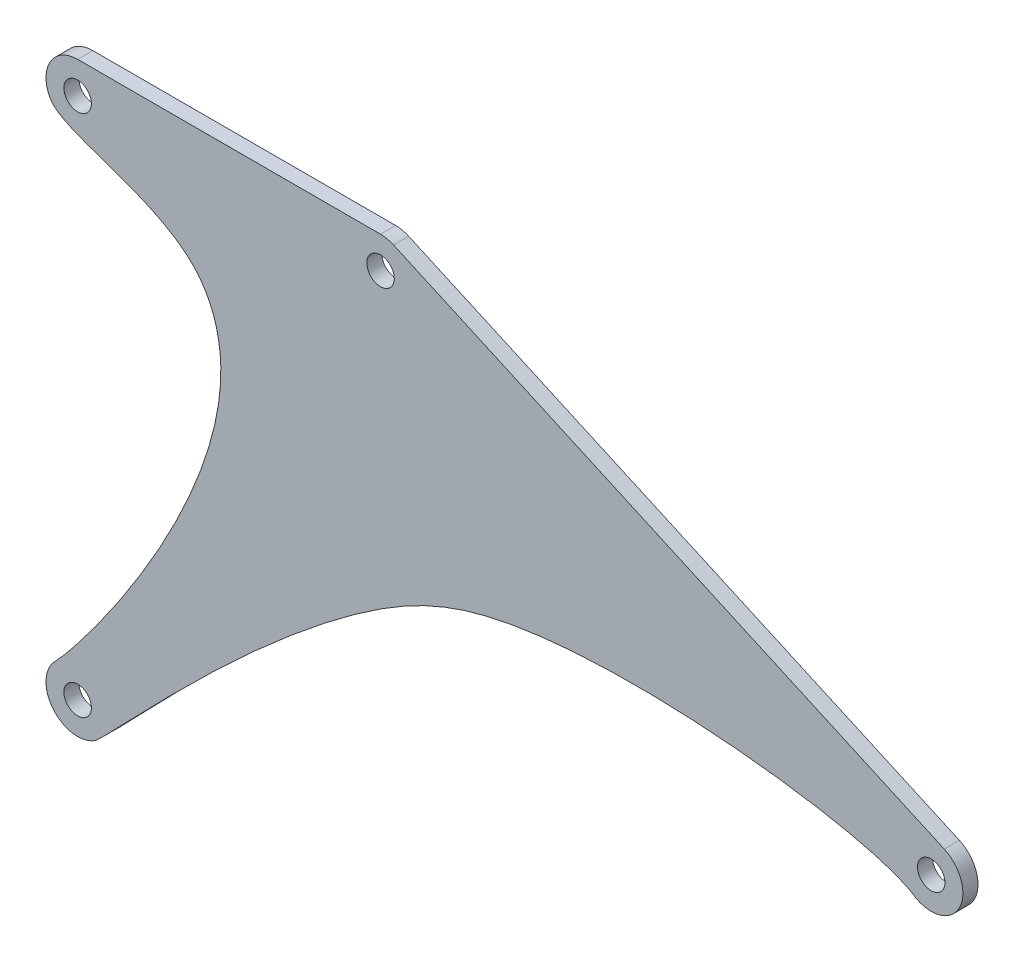
from build123d import *

# Parameters (mm, degrees)
SKETCH1_R       = 5
LINK_BCEF_DEPTH = 2.75


with BuildPart() as part:
    # Sketch1 → link_BCEF (new body, symmetric)
    with BuildSketch(Plane.XY):
        with BuildLine():
            Line((-110, 11.5), (0, 11.5))
            ThreePointArc((0, 11.5), (2.413335963, 11.243923227), (4.719193789, 10.48709731))
            Line((4.719193789, 10.48709731), (204.719193789, -79.51290269))
            ThreePointArc((204.719193789, -79.51290269), (210.037033264, -95.613195459), (193.535322949, -99.510938472))
            add(Edge.make_bspline(
                [(-103.605175934, -199.558045049), (-99.166641345, -196.588436969), (-37.747767195, -126.045876693), (58.834709745, -72.841025291), (177.378760182, -88.529166185), (193.535322949, -99.510938472)],
                knots=[0, 0, 0, 0, 0.472274196, 0.59836262, 1, 1, 1, 1], degree=3))
            ThreePointArc((-103.605175934, -199.558045049), (-118.826673208, -197.371556151), (-118.265297035, -182.004071979))
            add(Edge.make_bspline(
                [(-119.914835658, -5.8263225), (-114.934982102, -14.300695419), (-66.448192668, -18.69275386), (-46.813712441, -89.406939193), (-106.083618348, -169.412013562), (-118.265297035, -182.004071979)],
                knots=[0, 0, 0, 0, 0.300298834, 0.455611494, 1, 1, 1, 1], degree=3))
            ThreePointArc((-119.914835658, -5.8263225), (-119.981300235, 5.711711269), (-110, 11.5))
        make_face()
        Circle(SKETCH1_R, mode=Mode.SUBTRACT)
        with Locations((200, -90)):
            Circle(SKETCH1_R, mode=Mode.SUBTRACT)
        with Locations((-110, -190)):
            Circle(SKETCH1_R, mode=Mode.SUBTRACT)
        with Locations((-110, 0)):
            Circle(SKETCH1_R, mode=Mode.SUBTRACT)
    extrude(amount=LINK_BCEF_DEPTH, both=True)


solid = part.part
